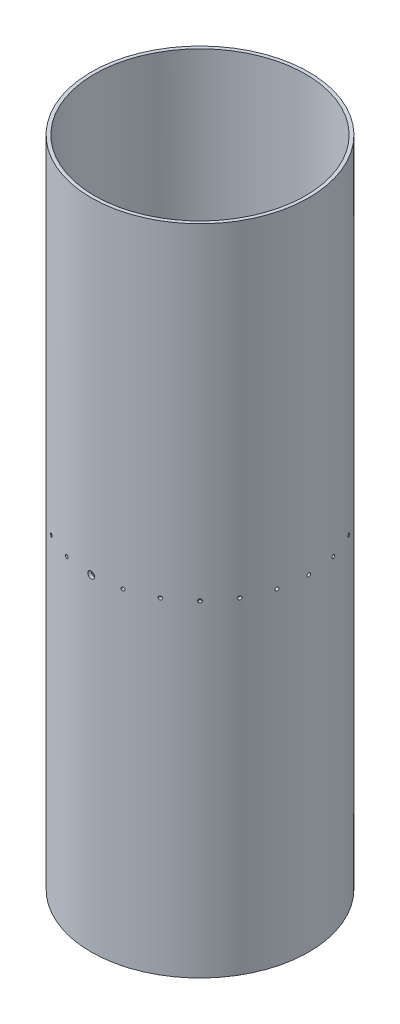
from build123d import *

# Parameters (mm, degrees)
SKETCH1_R               = 101.6
SKETCH1_R_2             = 98.425
BOSS_EXTRUDE1_DEPTH     = 609.6
SKETCH2_R               = 3.175
CUT_EXTRUDE1_DEPTH      = 102.6
CUT_EXTRUDE1_DEPTH_BACK = 102.6
SKETCH3_R               = 1.5875
CUT_EXTRUDE2_DEPTH      = 609.6
CIRPATTERN1_COUNT       = 24
SKETCH5_R               = 2.12471
CUT_EXTRUDE3_DEPTH      = 102.6000001
CUT_EXTRUDE3_DEPTH_BACK = 102.6000001


with BuildPart() as part:
    # Sketch1 → Boss-Extrude1 (new body)
    with BuildSketch(Plane(origin=(0, 0, 0), x_dir=(1, 0, 0), z_dir=(0, 1, 0))):
        Circle(SKETCH1_R)
        Circle(SKETCH1_R_2, mode=Mode.SUBTRACT)
    extrude(amount=BOSS_EXTRUDE1_DEPTH)

    # Sketch2 → Cut-Extrude1 (cut, two sides)
    with BuildSketch(Plane.XY) as cut_extrude1_sk:
        with Locations((0, 304.8)):
            Circle(SKETCH2_R)
    extrude(amount=CUT_EXTRUDE1_DEPTH, mode=Mode.SUBTRACT)
    extrude(cut_extrude1_sk.sketch, amount=-CUT_EXTRUDE1_DEPTH_BACK, mode=Mode.SUBTRACT)

    # Sketch3 → Cut-Extrude2 (cut)
    with BuildSketch(Plane(origin=(0, 0, 0), x_dir=(0, 0, -1), z_dir=(1, 0, 0))):
        with Locations((0, 304.8)):
            Circle(SKETCH3_R)
    cut_extrude2 = extrude(amount=-CUT_EXTRUDE2_DEPTH, mode=Mode.SUBTRACT)

    # CirPattern1: Cut-Extrude2 ×24 about axis
    cirpattern1_axis = Axis((0, 0, 0), (0, 1, 0))
    for i in range(1, CIRPATTERN1_COUNT):
        add(cut_extrude2.rotate(cirpattern1_axis, i * 360 / CIRPATTERN1_COUNT), mode=Mode.SUBTRACT)

    # Sketch5 → Cut-Extrude3 (cut, two sides)
    with BuildSketch(Plane.XY) as cut_extrude3_sk:
        with Locations((-84.7725, 422.89984)):
            Circle(SKETCH5_R)
    extrude(amount=CUT_EXTRUDE3_DEPTH, mode=Mode.SUBTRACT)
    extrude(cut_extrude3_sk.sketch, amount=-CUT_EXTRUDE3_DEPTH_BACK, mode=Mode.SUBTRACT)


solid = part.part
